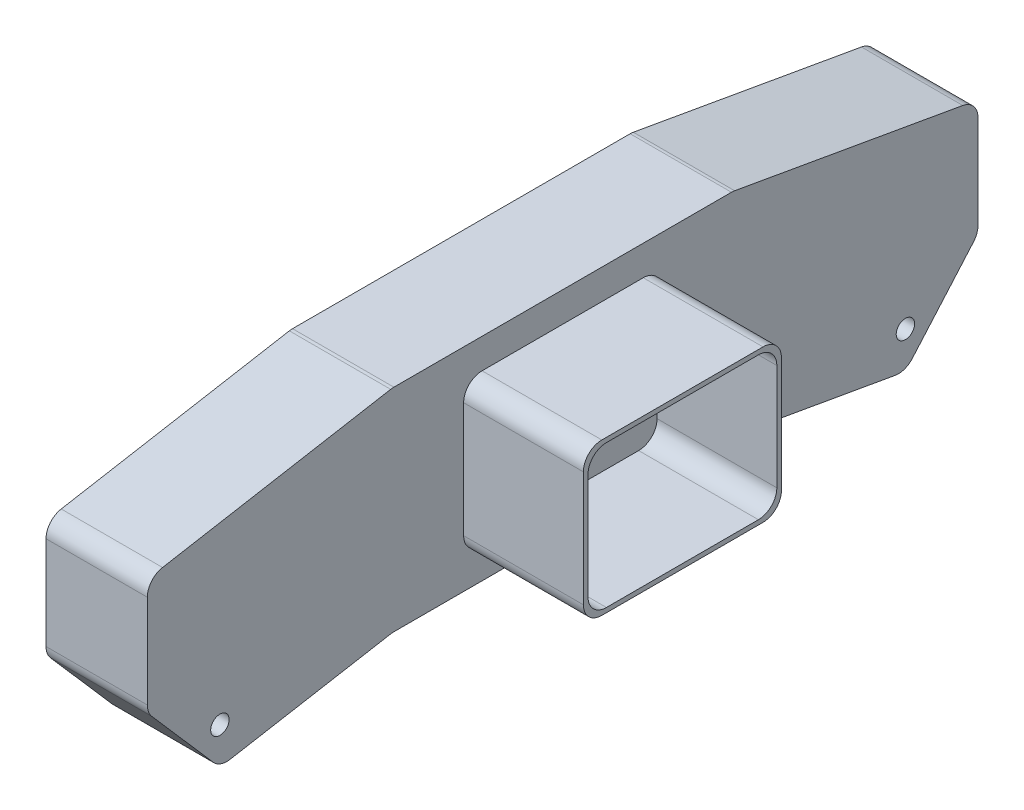
from build123d import *

# Parameters (mm, degrees)
SKETCH1_R           = 1
BOSS_EXTRUDE1_DEPTH = 11
SKETCH2_W           = 21.5
SKETCH2_H           = 16.5
SKETCH2_W_2         = 20.5
SKETCH2_H_2         = 15.5
EXTRUDE_THIN1_DEPTH = 13
FILLET1_R           = 2
FILLET2_R           = 2


with BuildPart() as part:
    # Sketch1 → Boss-Extrude1 (new body)
    with BuildSketch(Plane(origin=(0, 0, 0), x_dir=(0, 0, -1), z_dir=(1, 0, 0))):
        Polygon((-21.745526202, 8.298037657), (-48.335335533, 3.60953686), (-48.335335533, -8.949767561), (-40.456873509, -18.001277719), (-21.745526202, -14.701962343), (15.254473798, -14.701962343), (33.965821106, -18.001277719), (41.84428313, -8.949767561), (41.84428313, 3.60953686), (15.254473798, 8.298037657), align=None)
        with Locations((-40.456873509, -14.001277719)):
            Circle(SKETCH1_R, mode=Mode.SUBTRACT)
        with Locations((33.965821106, -14.001277719)):
            Circle(SKETCH1_R, mode=Mode.SUBTRACT)
    extrude(amount=BOSS_EXTRUDE1_DEPTH)

    # Sketch2 → Extrude-Thin1 (add)
    with BuildSketch(Plane(origin=(11, 0, 0), x_dir=(0, 0, -1), z_dir=(1, 0, 0))):
        with Locations((-3.245526202, -3.201962343)):
            Rectangle(SKETCH2_W, SKETCH2_H)
        with Locations((-3.245526202, -3.201962343)):
            Rectangle(SKETCH2_W_2, SKETCH2_H_2, mode=Mode.SUBTRACT)
    extrude(amount=EXTRUDE_THIN1_DEPTH)

    # Fillet1
    fillet1_edges = [part.edges().sort_by_distance(p)[0] for p in [
        (5.5, 8.298037657, -15.254473798),
        (5.5, 3.60953686, -41.84428313),
        (5.5, -8.949767561, -41.84428313),
        (5.5, -18.001277719, -33.965821106),
        (5.5, -14.701962343, -15.254473798),
        (5.5, -14.701962343, 21.745526202),
        (5.5, -18.001277719, 40.456873509),
        (5.5, -8.949767561, 48.335335533),
        (5.5, 3.60953686, 48.335335533),
        (5.5, 8.298037657, 21.745526202),
    ]]
    fillet(fillet1_edges, radius=FILLET1_R)

    # Fillet2
    fillet2_edges = [part.edges().sort_by_distance(p)[0] for p in [
        (17.5, -11.451962343, -7.504473798),
        (17.5, 5.048037657, -7.504473798),
        (17.5, 5.048037657, 13.995526202),
        (17.5, -11.451962343, 13.995526202),
        (17.5, 4.548037657, -7.004473798),
        (17.5, 4.548037657, 13.495526202),
        (17.5, -10.951962343, 13.495526202),
        (17.5, -10.951962343, -7.004473798),
    ]]
    fillet(fillet2_edges, radius=FILLET2_R)


solid = part.part
